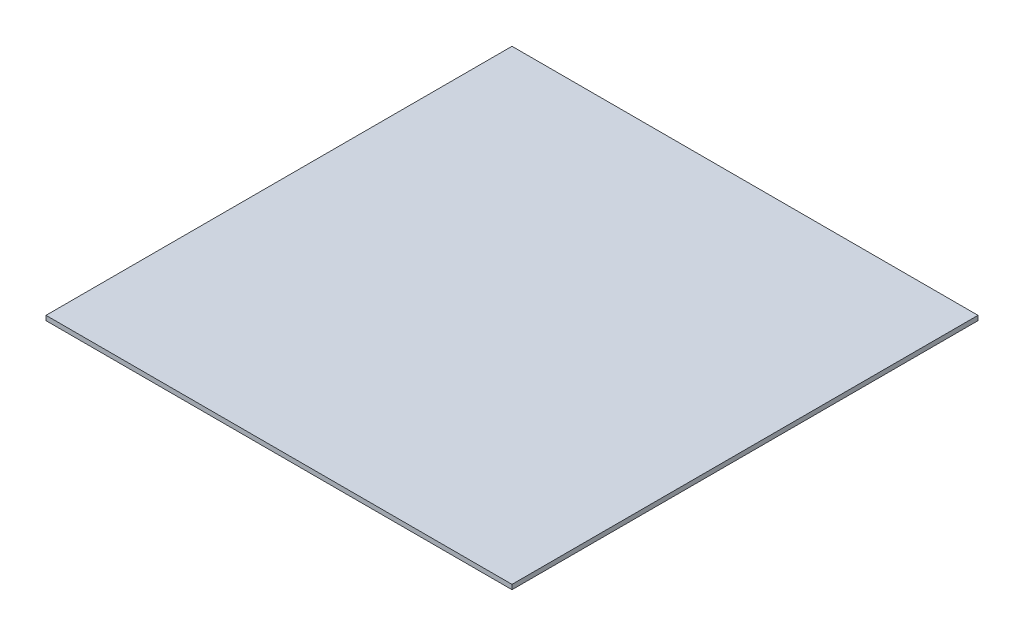
from build123d import *

# Parameters (mm, degrees)
SKETCH1_W           = 200
SKETCH1_H           = 200
BOSS_EXTRUDE1_DEPTH = 2


with BuildPart() as part:
    # Sketch1 → Boss-Extrude1 (new body)
    with BuildSketch(Plane(origin=(0, 0, 0), x_dir=(1, 0, 0), z_dir=(0, 1, 0))):
        with Locations((-93.816556055, -49.796738404)):
            Rectangle(SKETCH1_W, SKETCH1_H)
    extrude(amount=BOSS_EXTRUDE1_DEPTH)


solid = part.part
